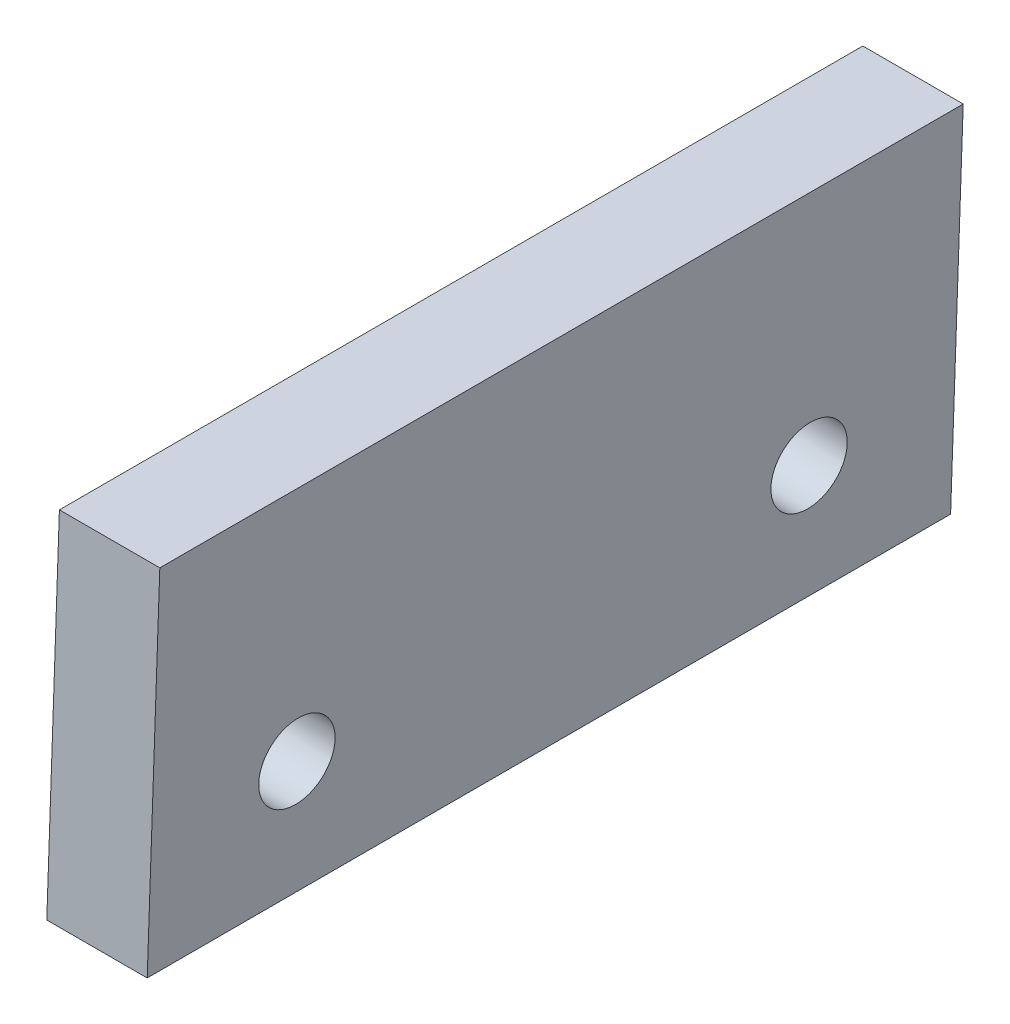
from build123d import *

# Parameters (mm, degrees)
BOSS_EXTRUDE2_DEPTH = 20
SKETCH4_R           = 0.95
CUT_EXTRUDE1_DEPTH  = 3.812572538


with BuildPart() as part:
    # Sketch2 → Boss-Extrude2 (new body)
    with BuildSketch(Plane.XY):
        Polygon((0, 0), (2.5, 0), (2.814286925, 9), (0.314286925, 9), align=None)
    extrude(amount=BOSS_EXTRUDE2_DEPTH)

    # Sketch4 → Cut-Extrude1 (cut, through all)
    with BuildSketch(Plane(origin=(0, 0, 0), x_dir=(0, 0, 1), z_dir=(-0.999390827, 0.034899497, 0))):
        with Locations((3.625, 3)):
            Circle(SKETCH4_R)
        with Locations((16.375, 3)):
            Circle(SKETCH4_R)
    extrude(amount=-CUT_EXTRUDE1_DEPTH, mode=Mode.SUBTRACT)


solid = part.part
